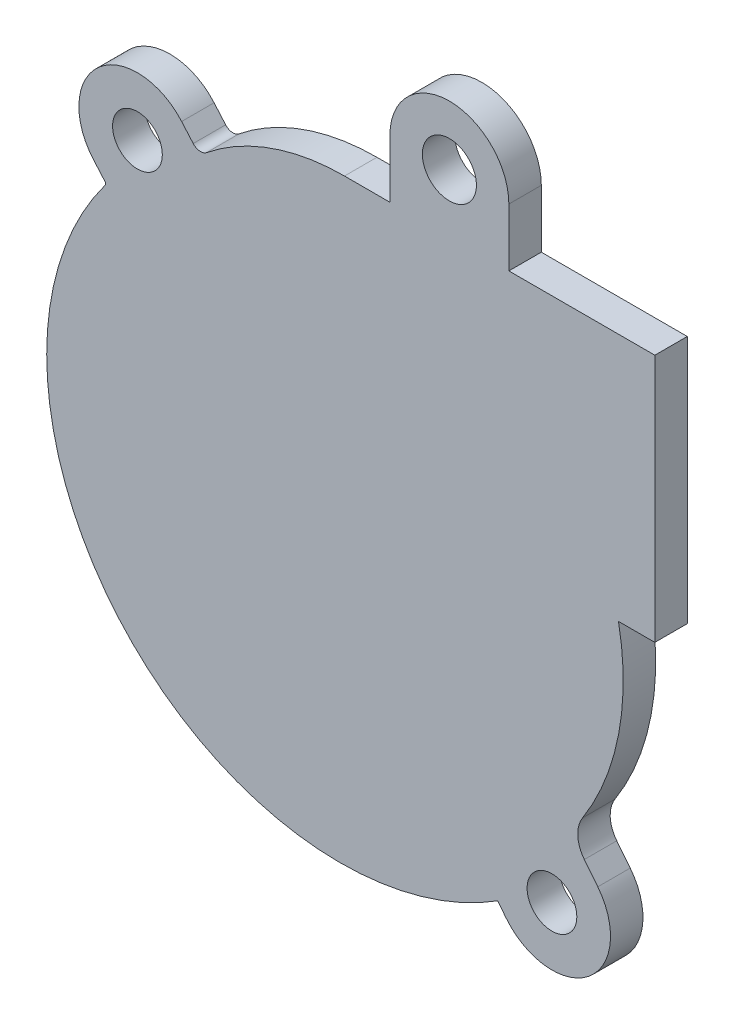
from build123d import *

# Parameters (mm, degrees)
SKETCH1_R           = 2.3
SKETCH1_R_2         = 2.5
BOSS_EXTRUDE1_DEPTH = 3


with BuildPart() as part:
    # Sketch1 → Boss-Extrude1 (new body)
    with BuildSketch(Plane.XY):
        with BuildLine():
            Line((-11.5, 21), (2, 21))
            Line((2, 21), (2, -2))
            Line((2, -2), (-1.360059051, -2))
            ThreePointArc((-1.360059051, -2), (-1.348623714, -11.019912453), (-4.688647717, -19.398646909))
            ThreePointArc((-4.688647717, -19.398646909), (-5.126699638, -21.05045095), (-4.522206104, -22.648866929))
            Line((-4.522206104, -22.648866929), (-3.277176831, -24.214083243))
            ThreePointArc((-3.277176831, -24.214083243), (-4.144083243, -31.822823169), (-11.752823169, -30.955916757))
            Line((-11.752823169, -30.955916757), (-12.538462624, -29.968232598))
            ThreePointArc((-12.538462624, -29.968232598), (-18.164899658, -32.689735637), (-24.264648783, -34.05224549))
            ThreePointArc((-24.264648783, -34.05224549), (-27.093039229, -34.2), (-29.921429675, -34.05224549))
            ThreePointArc((-29.921429675, -34.05224549), (-51.958319855, -17.944091524), (-48.851858813, 9.175035542))
            ThreePointArc((-48.851858813, 9.175035542), (-48.800272502, 9.340767339), (-48.864085593, 9.502186251))
            Line((-48.864085593, 9.502186251), (-49.933529172, 10.732440358))
            ThreePointArc((-49.933529172, 10.732440358), (-49.399336437, 18.371752377), (-41.760024419, 17.837559642))
            Line((-41.760024419, 17.837559642), (-40.69058084, 16.607305535))
            ThreePointArc((-40.69058084, 16.607305535), (-40.095055579, 16.303481207), (-39.455414432, 16.49795167))
            ThreePointArc((-39.455414432, 16.49795167), (-33.463302383, 19.841462143), (-26.7, 21))
            Line((-26.7, 21), (-22.5, 21))
            Line((-22.5, 21), (-22.5, 26.353946086))
            ThreePointArc((-22.5, 26.353946086), (-17, 31.853946086), (-11.5, 26.353946086))
            Line((-11.5, 26.353946086), (-11.5, 21))
        make_face()
        with Locations((-45.846776795, 14.285)):
            Circle(SKETCH1_R, mode=Mode.SUBTRACT)
        with Locations((-7.515, -27.585)):
            Circle(SKETCH1_R, mode=Mode.SUBTRACT)
        with Locations((-17, 26.353946086)):
            Circle(SKETCH1_R_2, mode=Mode.SUBTRACT)
    extrude(amount=BOSS_EXTRUDE1_DEPTH)


solid = part.part
